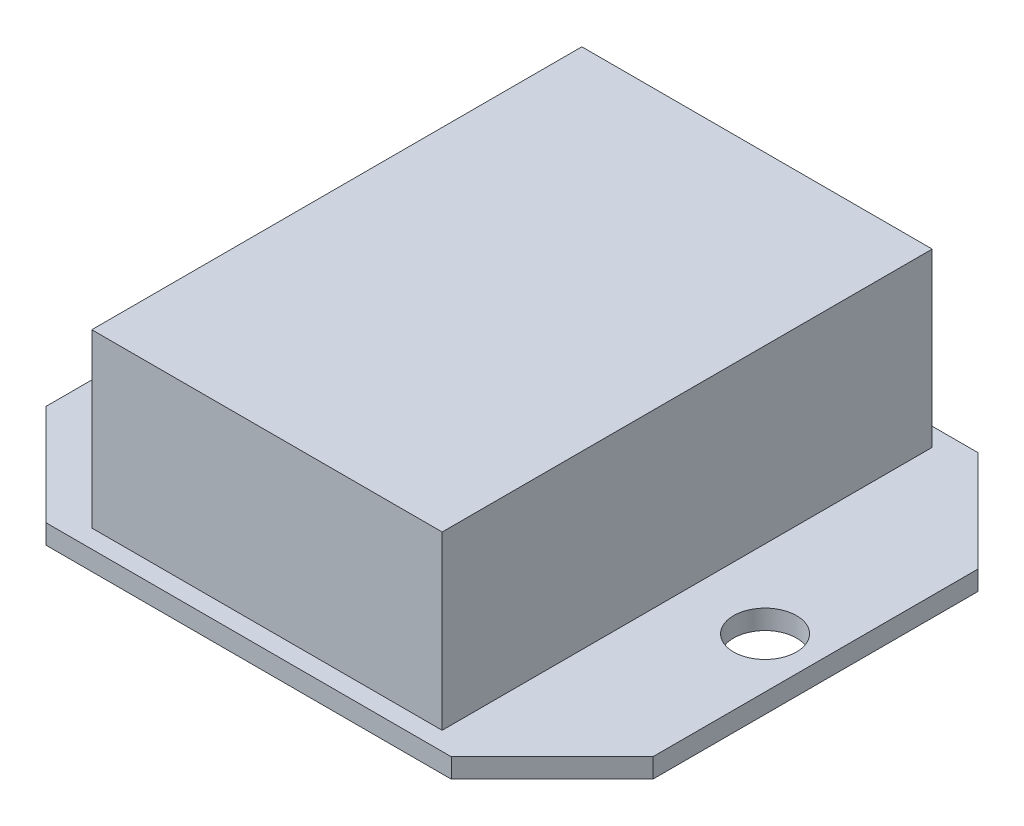
from build123d import *

# Parameters (mm, degrees)
SKETCH1_W           = 67.31
SKETCH1_H           = 58.42
BOSS_EXTRUDE1_DEPTH = 2.159
SKETCH2_W           = 38.862
SKETCH2_H           = 54.356
BOSS_EXTRUDE3_DEPTH = 19.05
CHAMFER1_SIZE       = 11.176


with BuildPart() as part:
    # Sketch1 → Boss-Extrude1 (new body)
    with BuildSketch(Plane(origin=(0, 0, 0), x_dir=(1, 0, 0), z_dir=(0, 1, 0))):
        Rectangle(SKETCH1_W, SKETCH1_H)
    extrude(amount=BOSS_EXTRUDE1_DEPTH)

    # Sketch2 → Boss-Extrude3 (add)
    with BuildSketch(Plane(origin=(0, 2.159, 0), x_dir=(1, 0, 0), z_dir=(0, 1, 0))):
        Rectangle(SKETCH2_W, SKETCH2_H)
    extrude(amount=BOSS_EXTRUDE3_DEPTH)

    # Sketch5 → #97 (0.275) Diameter Hole1 (revolve, cut)
    with BuildSketch(Plane(origin=(28.067, 2.159, 0), x_dir=(0, 0, 1), z_dir=(1, 0, 0))):
        Polygon((0, 0), (0, 6.162505712), (3.4925, 4.064), (3.4925, 0), align=None)
    f_97_0_275_diameter_hole1 = revolve(axis=Axis((28.067, 8.509, 0), (0, -1, 0)), mode=Mode.SUBTRACT)

    # Mirror1: #97 (0.275) Diameter Hole1 across plane
    add(f_97_0_275_diameter_hole1.mirror(Plane(origin=(0, 0, 0), x_dir=(0, 0, 1), z_dir=(1, 0, 0))), mode=Mode.SUBTRACT)

    # Chamfer1
    chamfer1_edges = [part.edges().sort_by_distance(p)[0] for p in [
        (33.655, 1.0795, 29.21),
        (-33.655, 1.0795, 29.21),
        (-33.655, 1.0795, -29.21),
        (33.655, 1.0795, -29.21),
    ]]
    chamfer(chamfer1_edges, length=CHAMFER1_SIZE)


solid = part.part
